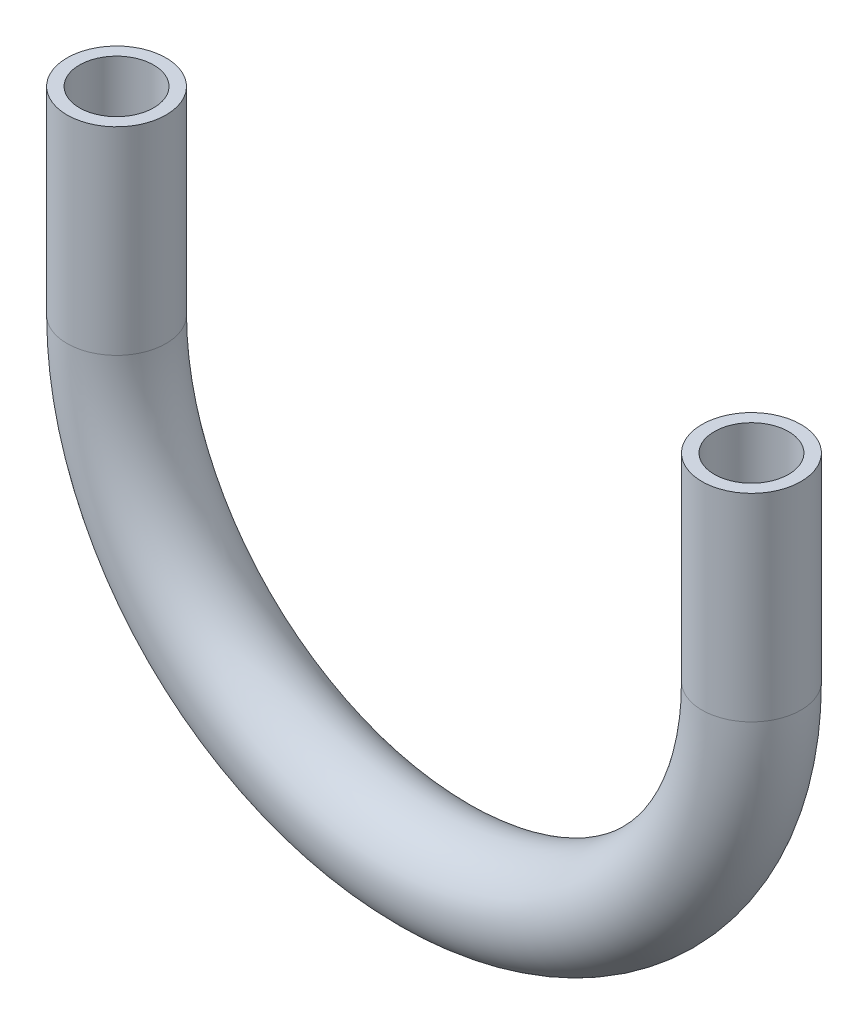
from build123d import *

# Parameters (mm, degrees)
SKETCH2_R   = 12.7
SKETCH2_R_2 = 9.525


with BuildPart() as part:
    # Sweep-Thin1: sweep along a path in Sketch1
    with BuildLine(Plane.XY) as sweep_thin1_path:
        Line((0, 0), (0, -50.8))
        ThreePointArc((0, -50.8), (81.460512212, -132.260512212), (162.921024424, -50.8))
        Line((162.921024424, -50.8), (162.921024424, 0))
    # Sketch2 → Sweep-Thin1 (sweep)
    with BuildSketch(Plane(origin=(0, 0, 0), x_dir=(1, 0, 0), z_dir=(0, 1, 0))):
        Circle(SKETCH2_R)
        Circle(SKETCH2_R_2, mode=Mode.SUBTRACT)
    sweep(path=sweep_thin1_path.line)


solid = part.part
